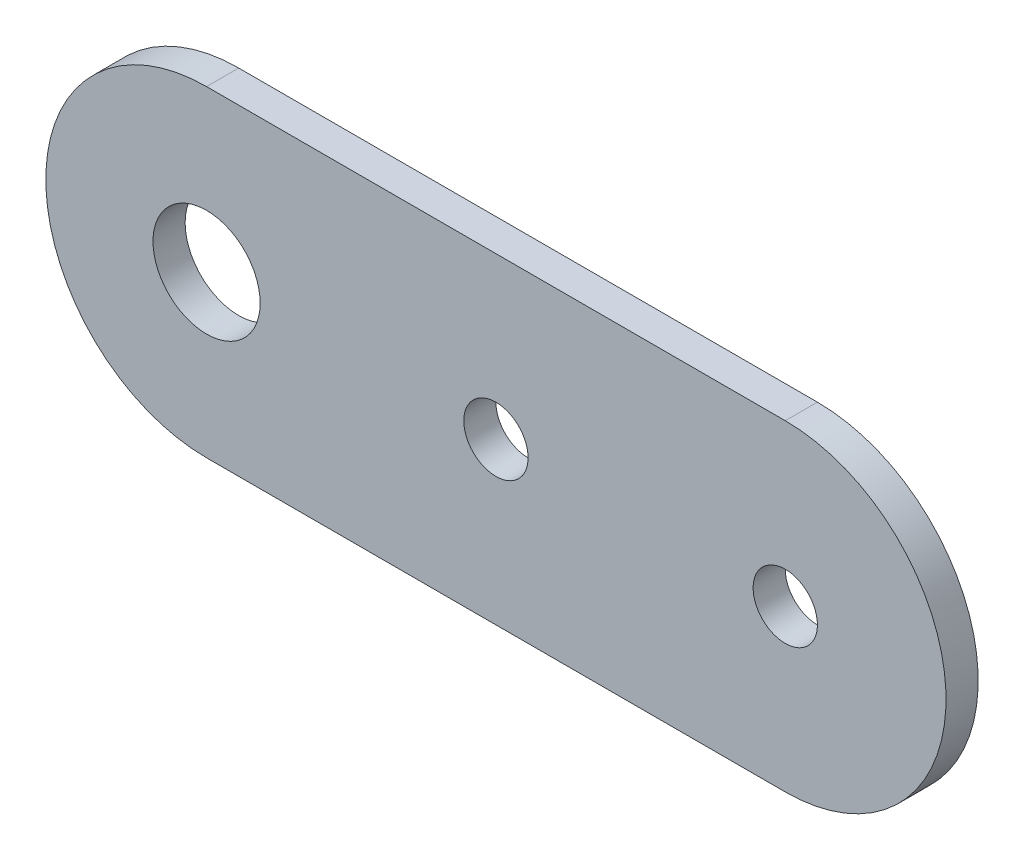
from build123d import *

# Parameters (mm, degrees)
BOSS_EXTRUDE1_DEPTH = 3
SKETCH2_R           = 5
SKETCH2_R_2         = 3
CUT_EXTRUDE1_DEPTH  = 3


with BuildPart() as part:
    # Sketch1 → Boss-Extrude1 (new body)
    with BuildSketch(Plane.XY):
        with BuildLine():
            Line((0, 15), (54, 15))
            ThreePointArc((54, 15), (69, 0), (54, -15))
            Line((54, -15), (0, -15))
            ThreePointArc((0, -15), (-15, 0), (0, 15))
        make_face()
    extrude(amount=BOSS_EXTRUDE1_DEPTH)

    # Sketch2 → Cut-Extrude1 (cut)
    with BuildSketch(Plane.XY.offset(3)):
        Circle(SKETCH2_R)
        with Locations((27, 0)):
            Circle(SKETCH2_R_2)
        with Locations((54, 0)):
            Circle(SKETCH2_R_2)
    extrude(amount=-CUT_EXTRUDE1_DEPTH, mode=Mode.SUBTRACT)


solid = part.part
